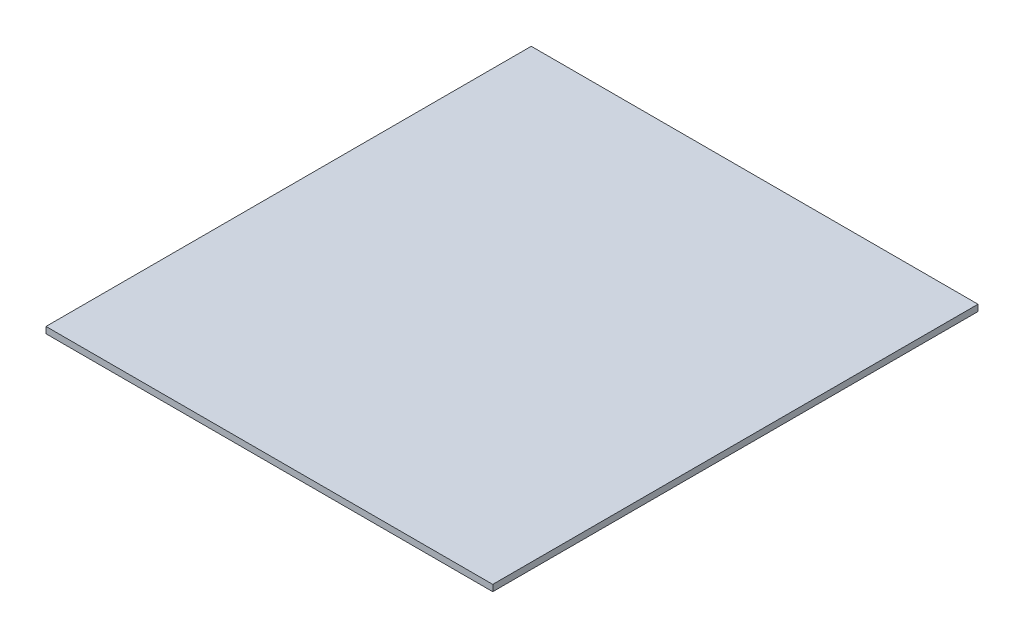
from build123d import *

# Parameters (mm, degrees)
SKETCH1_W           = 210
SKETCH1_H           = 228.092
BOSS_EXTRUDE1_DEPTH = 3


with BuildPart() as part:
    # Sketch1 → Boss-Extrude1 (new body)
    with BuildSketch(Plane(origin=(0, 0, 0), x_dir=(1, 0, 0), z_dir=(0, 1, 0))):
        with Locations((0, -114.046)):
            Rectangle(SKETCH1_W, SKETCH1_H)
    extrude(amount=BOSS_EXTRUDE1_DEPTH)


solid = part.part
